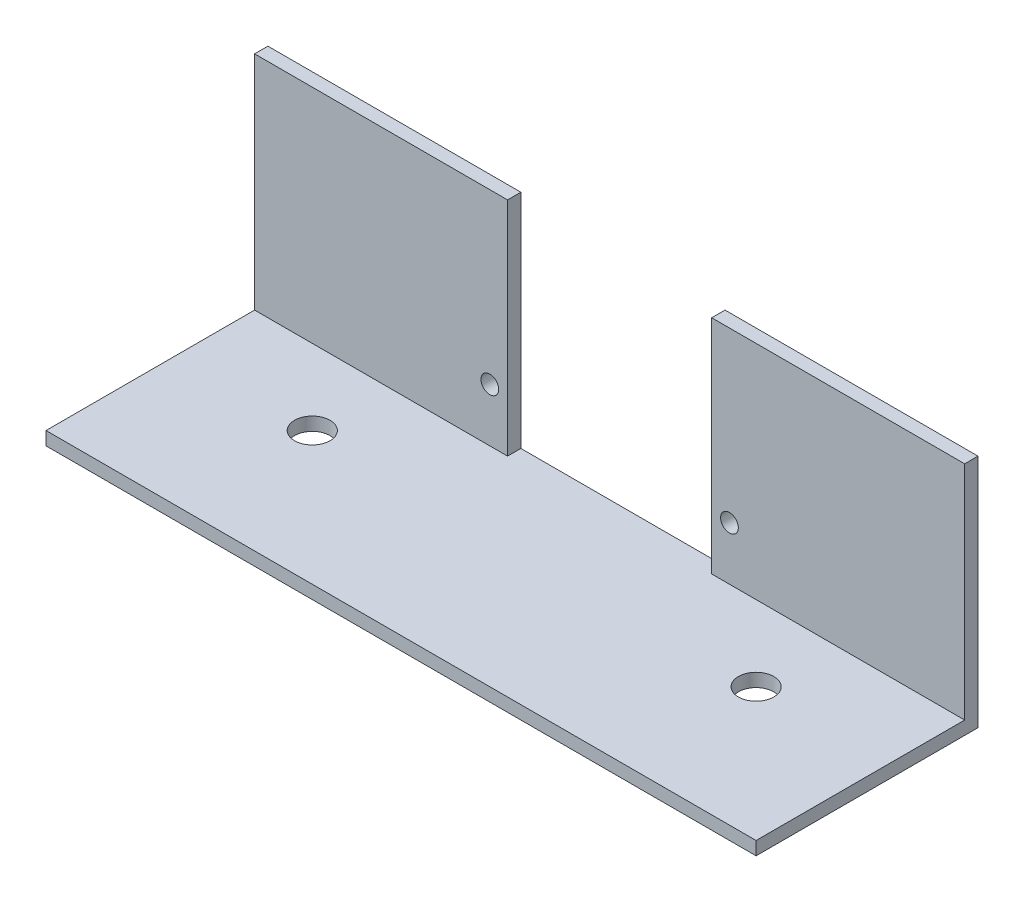
from build123d import *

# Parameters (mm, degrees)
SKETCH1_W           = 80
SKETCH1_H           = 25
SKETCH1_R           = 2
BOSS_EXTRUDE1_DEPTH = 1.5
SKETCH2_W           = 28.5
SKETCH2_H           = 1.5
BOSS_EXTRUDE2_DEPTH = 25
SKETCH3_R           = 1
CUT_EXTRUDE1_DEPTH  = 1.5


with BuildPart() as part:
    # Sketch1 → Boss-Extrude1 (new body)
    with BuildSketch(Plane(origin=(0, 0, 0), x_dir=(1, 0, 0), z_dir=(0, 1, 0))):
        Rectangle(SKETCH1_W, SKETCH1_H)
        with Locations((-25, 2.5)):
            Circle(SKETCH1_R, mode=Mode.SUBTRACT)
        with Locations((25, 2.5)):
            Circle(SKETCH1_R, mode=Mode.SUBTRACT)
    extrude(amount=BOSS_EXTRUDE1_DEPTH)

    # Sketch2 → Boss-Extrude2 (add)
    with BuildSketch(Plane(origin=(0, 1.5, 0), x_dir=(1, 0, 0), z_dir=(0, 1, 0))):
        with Locations((-25.75, 11.75)):
            Rectangle(SKETCH2_W, SKETCH2_H)
        with Locations((25.75, 11.75)):
            Rectangle(SKETCH2_W, SKETCH2_H)
    extrude(amount=BOSS_EXTRUDE2_DEPTH)

    # Sketch3 → Cut-Extrude1 (cut)
    with BuildSketch(Plane(origin=(0, 0, -12.5), x_dir=(-1, 0, 0), z_dir=(0, 0, -1))):
        with Locations((13.5, 7.5)):
            Circle(SKETCH3_R)
        with Locations((-13.5, 7.5)):
            Circle(SKETCH3_R)
    extrude(amount=-CUT_EXTRUDE1_DEPTH, mode=Mode.SUBTRACT)


solid = part.part
